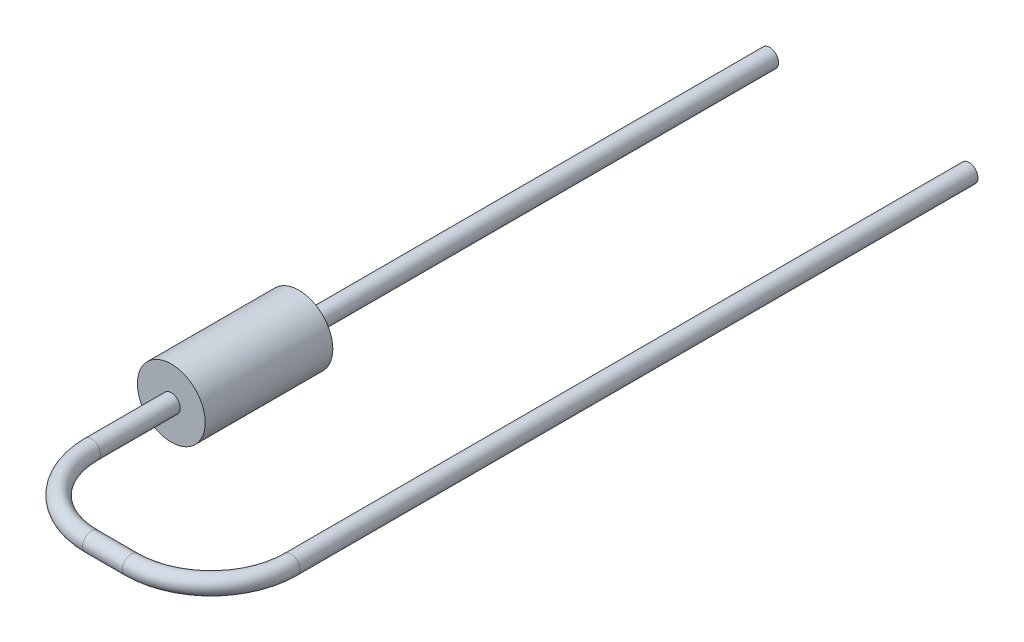
from build123d import *

# Parameters (mm, degrees)
SKETCH2_R           = 0.85
RESISTOR_BODY_DEPTH = 3.2
LEAD1_PROFILE_R     = 0.225
SKETCH6_R           = 0.225
LEAD2_DEPTH         = 11.8


with BuildPart() as part:
    # Sketch2 → Resistor Body (new body)
    with BuildSketch(Plane.XY):
        Circle(SKETCH2_R)
    extrude(amount=RESISTOR_BODY_DEPTH)

    # Lead1: sweep along a path in Lead1 Path
    with BuildLine(Plane.XZ) as lead1_path:
        Line((0, 3.2), (0, 5.2))
        ThreePointArc((0, 5.2), (0.585786438, 6.614213562), (2, 7.2))
        Line((2, 7.2), (3, 7.2))
        ThreePointArc((3, 7.2), (4.414213562, 6.614213562), (5, 5.2))
        Line((5, 5.2), (5, -11.8))
    # Lead1 Profile → Lead1 (sweep)
    with BuildSketch(Plane(origin=(0, 0, 3.2), x_dir=(-1, 0, 0), z_dir=(0, 0, 1))):
        Circle(LEAD1_PROFILE_R)
    sweep(path=lead1_path.line)

    # Sketch6 → Lead2 (add)
    with BuildSketch(Plane(origin=(0, 0, 0), x_dir=(1, 0, 0), z_dir=(0, 0, -1))):
        Circle(SKETCH6_R)
    extrude(amount=LEAD2_DEPTH)


solid = part.part
